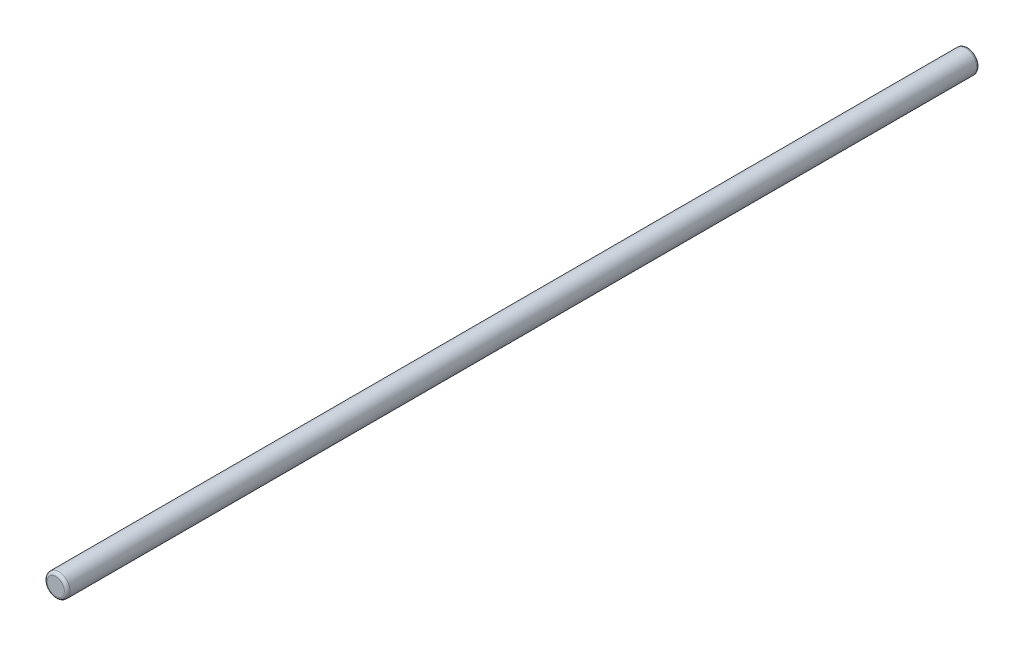
from build123d import *

# Parameters (mm, degrees)
SKETCH1_R      = 4
EXTRUDE2_DEPTH = 318.625
FILLET2_R      = 1
FILLET3_R      = 1


with BuildPart() as part:
    # Sketch1 → Extrude2 (new body)
    with BuildSketch(Plane.XY):
        Circle(SKETCH1_R)
    extrude(amount=EXTRUDE2_DEPTH)

    # Fillet2
    fillet2_edges = [part.edges().sort_by_distance(p)[0] for p in [
        (-4, 0, 0),
    ]]
    fillet(fillet2_edges, radius=FILLET2_R)

    # Fillet3
    fillet3_edges = [part.edges().sort_by_distance(p)[0] for p in [
        (-4, 0, 318.625),
    ]]
    fillet(fillet3_edges, radius=FILLET3_R)


solid = part.part
